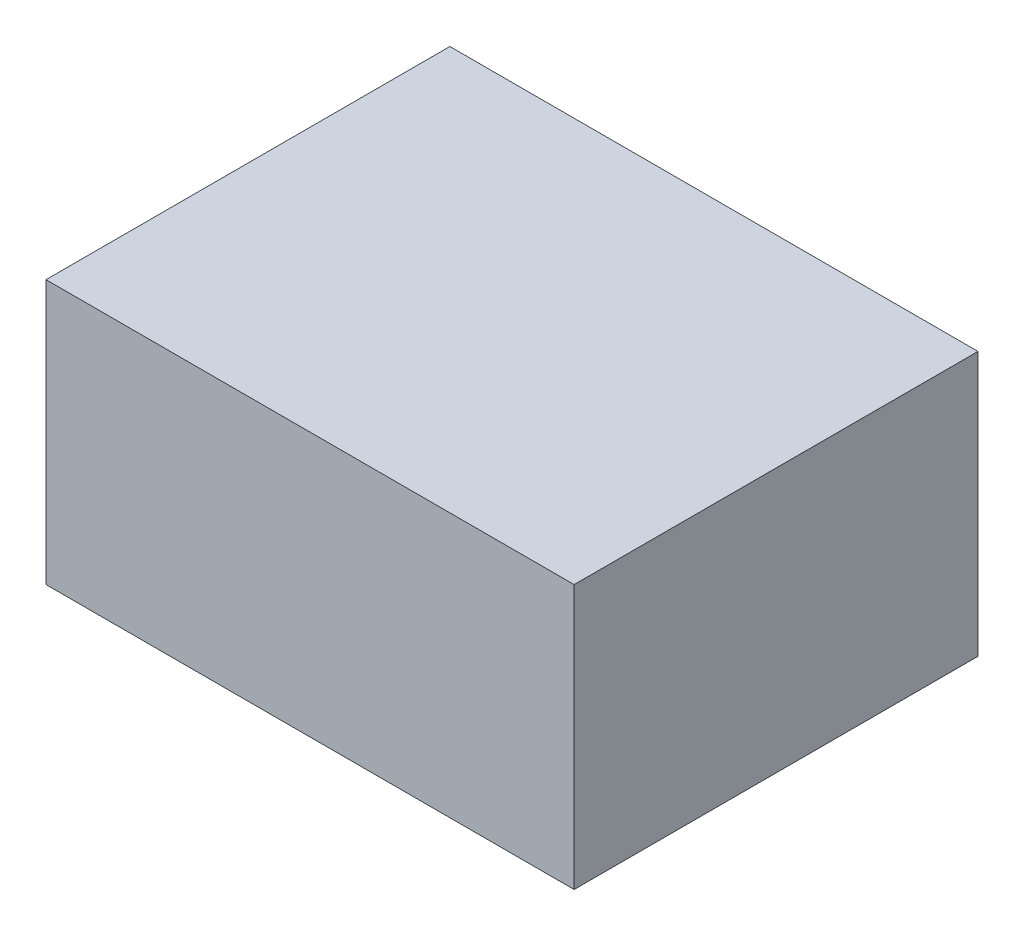
from build123d import *

# Parameters (mm, degrees)
SKETCH1_W           = 0.34
SKETCH1_H           = 0.26
BOSS_EXTRUDE1_DEPTH = 0.17


with BuildPart() as part:
    # Sketch1 → Boss-Extrude1 (new body)
    with BuildSketch(Plane(origin=(0, 0, 0), x_dir=(1, 0, 0), z_dir=(0, 1, 0))):
        Rectangle(SKETCH1_W, SKETCH1_H)
    extrude(amount=BOSS_EXTRUDE1_DEPTH)


solid = part.part
